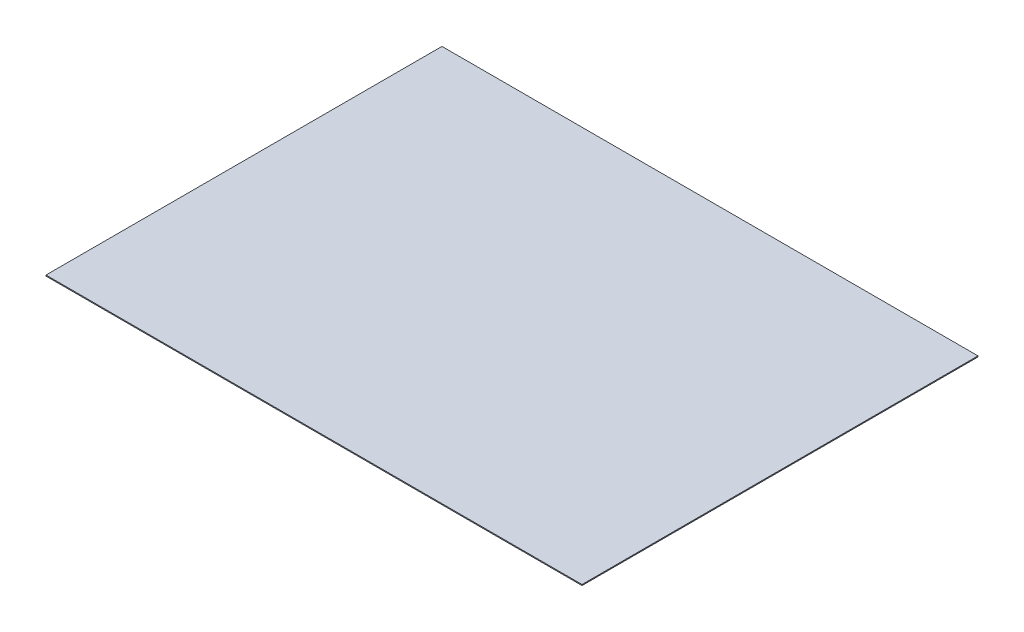
from build123d import *

# Parameters (mm, degrees)
SKETCH1_W           = 1616.075
SKETCH1_H           = 1193.8
BOSS_EXTRUDE1_DEPTH = 2.921


with BuildPart() as part:
    # Sketch1 → Boss-Extrude1 (new body)
    with BuildSketch(Plane(origin=(0, 0, 0), x_dir=(1, 0, 0), z_dir=(0, 1, 0))):
        with Locations((808.0375, 596.9)):
            Rectangle(SKETCH1_W, SKETCH1_H)
    extrude(amount=BOSS_EXTRUDE1_DEPTH)


solid = part.part
